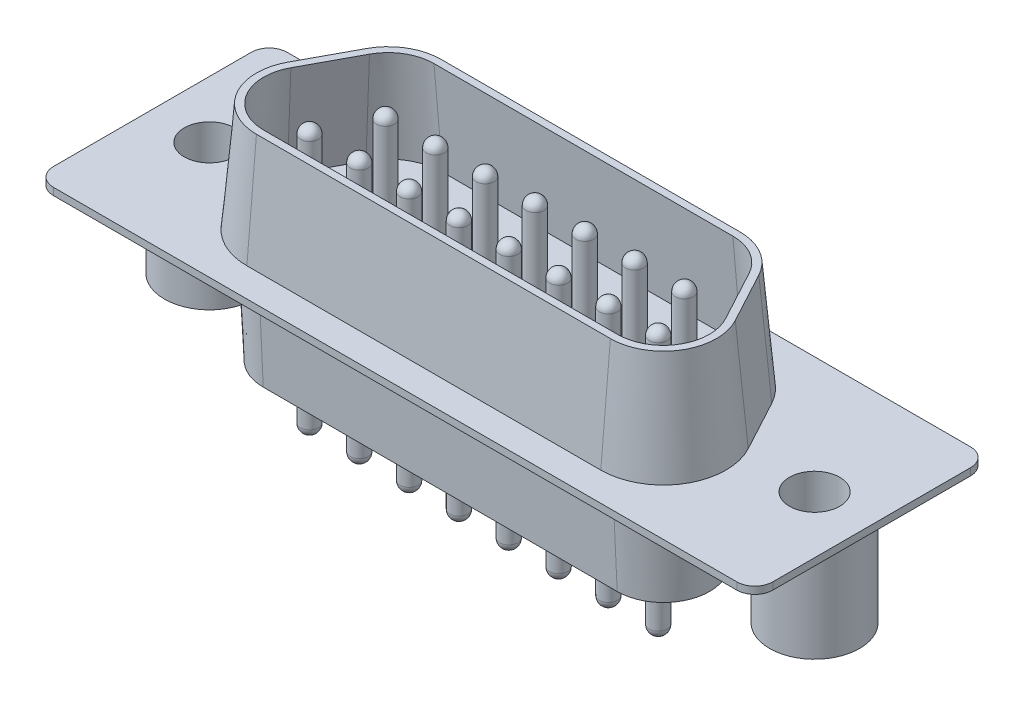
from build123d import *

# Parameters (mm, degrees)
SKETCH1_W                    = 40
SKETCH1_H                    = 0.4
BASE_EXTRUDE_DEPTH           = 5.08
BASE_EXTRUDE_DEPTH_BACK      = 7.92
FILLET1_R                    = 1
SKETCH3_R                    = 2.5
BOSS_EXTRUDE1_DEPTH          = 5.9
SKETCH2_R                    = 1.4
CUT_EXTRUDE1_DEPTH           = 32.509395424
BOSS_EXTRUDE2_DEPTH          = 5.9
BOSS_EXTRUDE2_TAPER          = 2.7
CUT_EXTRUDE2_DEPTH           = 0.01
SKETCH6_R                    = 0.5
BOSS_EXTRUDE3_DEPTH          = 3
DOME1_FACE_RADIUS            = 0.5
DOME1_HEIGHT                 = 0.5
LPATTERN2_COUNT              = 8
LPATTERN2_PITCH              = 2.77
LPATTERN2_COPY_1_FACE_RADIUS = 0.5
LPATTERN2_COPY_1_HEIGHT      = 0.5
LPATTERN2_COPY_2_FACE_RADIUS = 0.5
LPATTERN2_COPY_2_HEIGHT      = 0.5
LPATTERN2_COPY_3_FACE_RADIUS = 0.5
LPATTERN2_COPY_3_HEIGHT      = 0.5
LPATTERN2_COPY_4_FACE_RADIUS = 0.5
LPATTERN2_COPY_4_HEIGHT      = 0.5
LPATTERN2_COPY_5_FACE_RADIUS = 0.5
LPATTERN2_COPY_5_HEIGHT      = 0.5
LPATTERN2_COPY_6_FACE_RADIUS = 0.5
LPATTERN2_COPY_6_HEIGHT      = 0.5
LPATTERN2_COPY_7_FACE_RADIUS = 0.5
LPATTERN2_COPY_7_HEIGHT      = 0.5
SKETCH7_R                    = 0.5
BOSS_EXTRUDE4_DEPTH          = 3
DOME2_FACE_RADIUS            = 0.5
DOME2_HEIGHT                 = 0.5
LPATTERN4_COUNT              = 7
LPATTERN4_PITCH              = 2.77
LPATTERN4_COPY_1_FACE_RADIUS = 0.5
LPATTERN4_COPY_1_HEIGHT      = 0.5
LPATTERN4_COPY_2_FACE_RADIUS = 0.5
LPATTERN4_COPY_2_HEIGHT      = 0.5
LPATTERN4_COPY_3_FACE_RADIUS = 0.5
LPATTERN4_COPY_3_HEIGHT      = 0.5
LPATTERN4_COPY_4_FACE_RADIUS = 0.5
LPATTERN4_COPY_4_HEIGHT      = 0.5
LPATTERN4_COPY_5_FACE_RADIUS = 0.5
LPATTERN4_COPY_5_HEIGHT      = 0.5
LPATTERN4_COPY_6_FACE_RADIUS = 0.5
LPATTERN4_COPY_6_HEIGHT      = 0.5
BOSS_EXTRUDE5_DEPTH          = 6.07
BOSS_EXTRUDE5_TAPER          = 5
CUT_EXTRUDE3_DEPTH           = 5.47
CUT_EXTRUDE3_DRAFT           = 5
SKETCH10_R                   = 0.5
BOSS_EXTRUDE6_DEPTH          = 4
DOME3_FACE_RADIUS            = 0.5
DOME3_HEIGHT                 = 0.5
LPATTERN5_COPY_1_FACE_RADIUS = 0.5
LPATTERN5_COPY_1_HEIGHT      = 0.5
LPATTERN5_COPY_2_FACE_RADIUS = 0.5
LPATTERN5_COPY_2_HEIGHT      = 0.5
LPATTERN5_COPY_3_FACE_RADIUS = 0.5
LPATTERN5_COPY_3_HEIGHT      = 0.5
LPATTERN5_COPY_4_FACE_RADIUS = 0.5
LPATTERN5_COPY_4_HEIGHT      = 0.5
LPATTERN5_COPY_5_FACE_RADIUS = 0.5
LPATTERN5_COPY_5_HEIGHT      = 0.5
LPATTERN5_COPY_6_FACE_RADIUS = 0.5
LPATTERN5_COPY_6_HEIGHT      = 0.5
LPATTERN5_COPY_7_FACE_RADIUS = 0.5
LPATTERN5_COPY_7_HEIGHT      = 0.5
DOME4_FACE_RADIUS            = 0.5
DOME4_HEIGHT                 = 0.5
LPATTERN6_COPY_1_FACE_RADIUS = 0.5
LPATTERN6_COPY_1_HEIGHT      = 0.5
LPATTERN6_COPY_2_FACE_RADIUS = 0.5
LPATTERN6_COPY_2_HEIGHT      = 0.5
LPATTERN6_COPY_3_FACE_RADIUS = 0.5
LPATTERN6_COPY_3_HEIGHT      = 0.5
LPATTERN6_COPY_4_FACE_RADIUS = 0.5
LPATTERN6_COPY_4_HEIGHT      = 0.5
LPATTERN6_COPY_5_FACE_RADIUS = 0.5
LPATTERN6_COPY_5_HEIGHT      = 0.5
LPATTERN6_COPY_6_FACE_RADIUS = 0.5
LPATTERN6_COPY_6_HEIGHT      = 0.5


with BuildPart() as part:
    # Sketch1 → Base-Extrude (new, two sides)
    with BuildSketch(Plane.XY) as base_extrude_sk:
        with Locations((9.84, 6.1)):
            Rectangle(SKETCH1_W, SKETCH1_H)
    extrude(amount=BASE_EXTRUDE_DEPTH)
    extrude(base_extrude_sk.sketch, amount=-BASE_EXTRUDE_DEPTH_BACK)

    # Fillet1
    fillet1_edges = [part.edges().sort_by_distance(p)[0] for p in [
        (29.84, 6.1, 5.08),
        (-10.16, 6.1, -7.92),
        (29.84, 6.1, -7.92),
        (-10.16, 6.1, 5.08),
    ]]
    fillet(fillet1_edges, radius=FILLET1_R)

    # Sketch3 → Boss-Extrude1 (add)
    with BuildSketch(Plane(origin=(0, 5.9, 0), x_dir=(-1, 0, 0), z_dir=(0, 1, 0))):
        with Locations(Location((6.985, -1.42, 0), (0, 0, 90))):
            Circle(SKETCH3_R)
    boss_extrude1 = extrude(amount=-BOSS_EXTRUDE1_DEPTH)

    # Sketch2 → Cut-Extrude1 (cut, through all)
    with BuildSketch(Plane(origin=(0, 6.3, 0), x_dir=(-1, 0, 0), z_dir=(0, 1, 0))):
        with Locations(Location((6.985, -1.42, 0), (0, 0, 90))):
            Circle(SKETCH2_R)
    cut_extrude1 = extrude(amount=-CUT_EXTRUDE1_DEPTH, mode=Mode.SUBTRACT)

    # Mirror1: Boss-Extrude1, Cut-Extrude1 across plane
    add(boss_extrude1.mirror(Plane(origin=(9.84, 0, 0), x_dir=(0, 0, 1), z_dir=(1, 0, 0))))
    add(cut_extrude1.mirror(Plane(origin=(9.84, 0, 0), x_dir=(0, 0, 1), z_dir=(1, 0, 0))), mode=Mode.SUBTRACT)

    # Sketch4 → Boss-Extrude2 (add)
    with BuildSketch(Plane.XZ.offset(-5.9)):
        with BuildLine():
            ThreePointArc((18.15, -5.6892), (19.610774769, -5.286237461), (20.658354599, -4.191331879))
            Line((20.658354599, -4.191331879), (22.188354599, -1.351331879))
            ThreePointArc((22.188354599, -1.351331879), (22.126237461, 1.460774769), (19.68, 2.8492))
            Line((19.68, 2.8492), (0, 2.8492))
            ThreePointArc((0, 2.8492), (-2.446237461, 1.460774769), (-2.508354599, -1.351331879))
            Line((-2.508354599, -1.351331879), (-0.978354599, -4.191331879))
            ThreePointArc((-0.978354599, -4.191331879), (0.069225231, -5.286237461), (1.53, -5.6892))
            Line((1.53, -5.6892), (18.15, -5.6892))
        make_face()
    extrude(amount=BOSS_EXTRUDE2_DEPTH, taper=BOSS_EXTRUDE2_TAPER)

    # Sketch5 → Cut-Extrude2 (cut)
    with BuildSketch(Plane.XZ):
        with BuildLine():
            Line((20.0612541, -3.869654498), (21.5912541, -1.029654498))
            ThreePointArc((21.5912541, -1.029654498), (21.543923617, 1.113045089), (19.68, 2.170963063))
            Line((19.68, 2.170963063), (0, 2.170963063))
            ThreePointArc((0, 2.170963063), (-1.863923617, 1.113045089), (-1.9112541, -1.029654498))
            Line((-1.9112541, -1.029654498), (-0.3812541, -3.869654498))
            ThreePointArc((-0.3812541, -3.869654498), (0.416954911, -4.703923617), (1.53, -5.010963063))
            Line((1.53, -5.010963063), (18.15, -5.010963063))
            ThreePointArc((18.15, -5.010963063), (19.263045089, -4.703923617), (20.0612541, -3.869654498))
        make_face()
    extrude(amount=-CUT_EXTRUDE2_DEPTH, mode=Mode.SUBTRACT)

    # Sketch6 → Boss-Extrude3 (add)
    with BuildSketch(Plane.XZ.offset(-0.01)):
        with Locations(Location((0, 0, 0), (0, 0, 270))):
            Circle(SKETCH6_R)
    boss_extrude3 = extrude(amount=BOSS_EXTRUDE3_DEPTH)

    # Dome1: a dome of height H over a round flat face of radius A is a cap of a sphere of radius (A * A + H * H) / (2 * H)
    dome1_r = (DOME1_FACE_RADIUS * DOME1_FACE_RADIUS + DOME1_HEIGHT * DOME1_HEIGHT) / (2 * DOME1_HEIGHT)
    dome1_base = Plane((0, -2.99, 0), z_dir=(0, -1, 0))
    with Locations(dome1_base.offset(DOME1_HEIGHT - dome1_r)):
        dome1_ball = Sphere(dome1_r, mode=Mode.PRIVATE)
    add(split(dome1_ball, bisect_by=dome1_base, keep=Keep.TOP, mode=Mode.PRIVATE))

    # LPattern2: Boss-Extrude3 ×8
    with Locations(*[(i * LPATTERN2_PITCH, 0, 0) for i in range(1, LPATTERN2_COUNT)]):
        add(boss_extrude3)

    # LPattern2 copy 1: a dome of height H over a round flat face of radius A is a cap of a sphere of radius (A * A + H * H) / (2 * H)
    lpattern2_copy_1_r = (LPATTERN2_COPY_1_FACE_RADIUS * LPATTERN2_COPY_1_FACE_RADIUS + LPATTERN2_COPY_1_HEIGHT * LPATTERN2_COPY_1_HEIGHT) / (2 * LPATTERN2_COPY_1_HEIGHT)
    lpattern2_copy_1_base = Plane((2.77, -2.99, 0), z_dir=(0, -1, 0))
    with Locations(lpattern2_copy_1_base.offset(LPATTERN2_COPY_1_HEIGHT - lpattern2_copy_1_r)):
        lpattern2_copy_1_ball = Sphere(lpattern2_copy_1_r, mode=Mode.PRIVATE)
    add(split(lpattern2_copy_1_ball, bisect_by=lpattern2_copy_1_base, keep=Keep.TOP, mode=Mode.PRIVATE))

    # LPattern2 copy 2: a dome of height H over a round flat face of radius A is a cap of a sphere of radius (A * A + H * H) / (2 * H)
    lpattern2_copy_2_r = (LPATTERN2_COPY_2_FACE_RADIUS * LPATTERN2_COPY_2_FACE_RADIUS + LPATTERN2_COPY_2_HEIGHT * LPATTERN2_COPY_2_HEIGHT) / (2 * LPATTERN2_COPY_2_HEIGHT)
    lpattern2_copy_2_base = Plane((5.54, -2.99, 0), z_dir=(0, -1, 0))
    with Locations(lpattern2_copy_2_base.offset(LPATTERN2_COPY_2_HEIGHT - lpattern2_copy_2_r)):
        lpattern2_copy_2_ball = Sphere(lpattern2_copy_2_r, mode=Mode.PRIVATE)
    add(split(lpattern2_copy_2_ball, bisect_by=lpattern2_copy_2_base, keep=Keep.TOP, mode=Mode.PRIVATE))

    # LPattern2 copy 3: a dome of height H over a round flat face of radius A is a cap of a sphere of radius (A * A + H * H) / (2 * H)
    lpattern2_copy_3_r = (LPATTERN2_COPY_3_FACE_RADIUS * LPATTERN2_COPY_3_FACE_RADIUS + LPATTERN2_COPY_3_HEIGHT * LPATTERN2_COPY_3_HEIGHT) / (2 * LPATTERN2_COPY_3_HEIGHT)
    lpattern2_copy_3_base = Plane((8.31, -2.99, 0), z_dir=(0, -1, 0))
    with Locations(lpattern2_copy_3_base.offset(LPATTERN2_COPY_3_HEIGHT - lpattern2_copy_3_r)):
        lpattern2_copy_3_ball = Sphere(lpattern2_copy_3_r, mode=Mode.PRIVATE)
    add(split(lpattern2_copy_3_ball, bisect_by=lpattern2_copy_3_base, keep=Keep.TOP, mode=Mode.PRIVATE))

    # LPattern2 copy 4: a dome of height H over a round flat face of radius A is a cap of a sphere of radius (A * A + H * H) / (2 * H)
    lpattern2_copy_4_r = (LPATTERN2_COPY_4_FACE_RADIUS * LPATTERN2_COPY_4_FACE_RADIUS + LPATTERN2_COPY_4_HEIGHT * LPATTERN2_COPY_4_HEIGHT) / (2 * LPATTERN2_COPY_4_HEIGHT)
    lpattern2_copy_4_base = Plane((11.08, -2.99, 0), z_dir=(0, -1, 0))
    with Locations(lpattern2_copy_4_base.offset(LPATTERN2_COPY_4_HEIGHT - lpattern2_copy_4_r)):
        lpattern2_copy_4_ball = Sphere(lpattern2_copy_4_r, mode=Mode.PRIVATE)
    add(split(lpattern2_copy_4_ball, bisect_by=lpattern2_copy_4_base, keep=Keep.TOP, mode=Mode.PRIVATE))

    # LPattern2 copy 5: a dome of height H over a round flat face of radius A is a cap of a sphere of radius (A * A + H * H) / (2 * H)
    lpattern2_copy_5_r = (LPATTERN2_COPY_5_FACE_RADIUS * LPATTERN2_COPY_5_FACE_RADIUS + LPATTERN2_COPY_5_HEIGHT * LPATTERN2_COPY_5_HEIGHT) / (2 * LPATTERN2_COPY_5_HEIGHT)
    lpattern2_copy_5_base = Plane((13.85, -2.99, 0), z_dir=(0, -1, 0))
    with Locations(lpattern2_copy_5_base.offset(LPATTERN2_COPY_5_HEIGHT - lpattern2_copy_5_r)):
        lpattern2_copy_5_ball = Sphere(lpattern2_copy_5_r, mode=Mode.PRIVATE)
    add(split(lpattern2_copy_5_ball, bisect_by=lpattern2_copy_5_base, keep=Keep.TOP, mode=Mode.PRIVATE))

    # LPattern2 copy 6: a dome of height H over a round flat face of radius A is a cap of a sphere of radius (A * A + H * H) / (2 * H)
    lpattern2_copy_6_r = (LPATTERN2_COPY_6_FACE_RADIUS * LPATTERN2_COPY_6_FACE_RADIUS + LPATTERN2_COPY_6_HEIGHT * LPATTERN2_COPY_6_HEIGHT) / (2 * LPATTERN2_COPY_6_HEIGHT)
    lpattern2_copy_6_base = Plane((16.62, -2.99, 0), z_dir=(0, -1, 0))
    with Locations(lpattern2_copy_6_base.offset(LPATTERN2_COPY_6_HEIGHT - lpattern2_copy_6_r)):
        lpattern2_copy_6_ball = Sphere(lpattern2_copy_6_r, mode=Mode.PRIVATE)
    add(split(lpattern2_copy_6_ball, bisect_by=lpattern2_copy_6_base, keep=Keep.TOP, mode=Mode.PRIVATE))

    # LPattern2 copy 7: a dome of height H over a round flat face of radius A is a cap of a sphere of radius (A * A + H * H) / (2 * H)
    lpattern2_copy_7_r = (LPATTERN2_COPY_7_FACE_RADIUS * LPATTERN2_COPY_7_FACE_RADIUS + LPATTERN2_COPY_7_HEIGHT * LPATTERN2_COPY_7_HEIGHT) / (2 * LPATTERN2_COPY_7_HEIGHT)
    lpattern2_copy_7_base = Plane((19.39, -2.99, 0), z_dir=(0, -1, 0))
    with Locations(lpattern2_copy_7_base.offset(LPATTERN2_COPY_7_HEIGHT - lpattern2_copy_7_r)):
        lpattern2_copy_7_ball = Sphere(lpattern2_copy_7_r, mode=Mode.PRIVATE)
    add(split(lpattern2_copy_7_ball, bisect_by=lpattern2_copy_7_base, keep=Keep.TOP, mode=Mode.PRIVATE))

    # Sketch7 → Boss-Extrude4 (add)
    with BuildSketch(Plane.XZ.offset(-0.01)):
        with Locations(Location((1.385, -2.84, 0), (0, 0, 270))):
            Circle(SKETCH7_R)
    boss_extrude4 = extrude(amount=BOSS_EXTRUDE4_DEPTH)

    # Dome2: a dome of height H over a round flat face of radius A is a cap of a sphere of radius (A * A + H * H) / (2 * H)
    dome2_r = (DOME2_FACE_RADIUS * DOME2_FACE_RADIUS + DOME2_HEIGHT * DOME2_HEIGHT) / (2 * DOME2_HEIGHT)
    dome2_base = Plane((1.385, -2.99, -2.84), z_dir=(0, -1, 0))
    with Locations(dome2_base.offset(DOME2_HEIGHT - dome2_r)):
        dome2_ball = Sphere(dome2_r, mode=Mode.PRIVATE)
    add(split(dome2_ball, bisect_by=dome2_base, keep=Keep.TOP, mode=Mode.PRIVATE))

    # LPattern4: Boss-Extrude4 ×7
    with Locations(*[(i * LPATTERN4_PITCH, 0, 0) for i in range(1, LPATTERN4_COUNT)]):
        add(boss_extrude4)

    # LPattern4 copy 1: a dome of height H over a round flat face of radius A is a cap of a sphere of radius (A * A + H * H) / (2 * H)
    lpattern4_copy_1_r = (LPATTERN4_COPY_1_FACE_RADIUS * LPATTERN4_COPY_1_FACE_RADIUS + LPATTERN4_COPY_1_HEIGHT * LPATTERN4_COPY_1_HEIGHT) / (2 * LPATTERN4_COPY_1_HEIGHT)
    lpattern4_copy_1_base = Plane((4.155, -2.99, -2.84), z_dir=(0, -1, 0))
    with Locations(lpattern4_copy_1_base.offset(LPATTERN4_COPY_1_HEIGHT - lpattern4_copy_1_r)):
        lpattern4_copy_1_ball = Sphere(lpattern4_copy_1_r, mode=Mode.PRIVATE)
    add(split(lpattern4_copy_1_ball, bisect_by=lpattern4_copy_1_base, keep=Keep.TOP, mode=Mode.PRIVATE))

    # LPattern4 copy 2: a dome of height H over a round flat face of radius A is a cap of a sphere of radius (A * A + H * H) / (2 * H)
    lpattern4_copy_2_r = (LPATTERN4_COPY_2_FACE_RADIUS * LPATTERN4_COPY_2_FACE_RADIUS + LPATTERN4_COPY_2_HEIGHT * LPATTERN4_COPY_2_HEIGHT) / (2 * LPATTERN4_COPY_2_HEIGHT)
    lpattern4_copy_2_base = Plane((6.925, -2.99, -2.84), z_dir=(0, -1, 0))
    with Locations(lpattern4_copy_2_base.offset(LPATTERN4_COPY_2_HEIGHT - lpattern4_copy_2_r)):
        lpattern4_copy_2_ball = Sphere(lpattern4_copy_2_r, mode=Mode.PRIVATE)
    add(split(lpattern4_copy_2_ball, bisect_by=lpattern4_copy_2_base, keep=Keep.TOP, mode=Mode.PRIVATE))

    # LPattern4 copy 3: a dome of height H over a round flat face of radius A is a cap of a sphere of radius (A * A + H * H) / (2 * H)
    lpattern4_copy_3_r = (LPATTERN4_COPY_3_FACE_RADIUS * LPATTERN4_COPY_3_FACE_RADIUS + LPATTERN4_COPY_3_HEIGHT * LPATTERN4_COPY_3_HEIGHT) / (2 * LPATTERN4_COPY_3_HEIGHT)
    lpattern4_copy_3_base = Plane((9.695, -2.99, -2.84), z_dir=(0, -1, 0))
    with Locations(lpattern4_copy_3_base.offset(LPATTERN4_COPY_3_HEIGHT - lpattern4_copy_3_r)):
        lpattern4_copy_3_ball = Sphere(lpattern4_copy_3_r, mode=Mode.PRIVATE)
    add(split(lpattern4_copy_3_ball, bisect_by=lpattern4_copy_3_base, keep=Keep.TOP, mode=Mode.PRIVATE))

    # LPattern4 copy 4: a dome of height H over a round flat face of radius A is a cap of a sphere of radius (A * A + H * H) / (2 * H)
    lpattern4_copy_4_r = (LPATTERN4_COPY_4_FACE_RADIUS * LPATTERN4_COPY_4_FACE_RADIUS + LPATTERN4_COPY_4_HEIGHT * LPATTERN4_COPY_4_HEIGHT) / (2 * LPATTERN4_COPY_4_HEIGHT)
    lpattern4_copy_4_base = Plane((12.465, -2.99, -2.84), z_dir=(0, -1, 0))
    with Locations(lpattern4_copy_4_base.offset(LPATTERN4_COPY_4_HEIGHT - lpattern4_copy_4_r)):
        lpattern4_copy_4_ball = Sphere(lpattern4_copy_4_r, mode=Mode.PRIVATE)
    add(split(lpattern4_copy_4_ball, bisect_by=lpattern4_copy_4_base, keep=Keep.TOP, mode=Mode.PRIVATE))

    # LPattern4 copy 5: a dome of height H over a round flat face of radius A is a cap of a sphere of radius (A * A + H * H) / (2 * H)
    lpattern4_copy_5_r = (LPATTERN4_COPY_5_FACE_RADIUS * LPATTERN4_COPY_5_FACE_RADIUS + LPATTERN4_COPY_5_HEIGHT * LPATTERN4_COPY_5_HEIGHT) / (2 * LPATTERN4_COPY_5_HEIGHT)
    lpattern4_copy_5_base = Plane((15.235, -2.99, -2.84), z_dir=(0, -1, 0))
    with Locations(lpattern4_copy_5_base.offset(LPATTERN4_COPY_5_HEIGHT - lpattern4_copy_5_r)):
        lpattern4_copy_5_ball = Sphere(lpattern4_copy_5_r, mode=Mode.PRIVATE)
    add(split(lpattern4_copy_5_ball, bisect_by=lpattern4_copy_5_base, keep=Keep.TOP, mode=Mode.PRIVATE))

    # LPattern4 copy 6: a dome of height H over a round flat face of radius A is a cap of a sphere of radius (A * A + H * H) / (2 * H)
    lpattern4_copy_6_r = (LPATTERN4_COPY_6_FACE_RADIUS * LPATTERN4_COPY_6_FACE_RADIUS + LPATTERN4_COPY_6_HEIGHT * LPATTERN4_COPY_6_HEIGHT) / (2 * LPATTERN4_COPY_6_HEIGHT)
    lpattern4_copy_6_base = Plane((18.005, -2.99, -2.84), z_dir=(0, -1, 0))
    with Locations(lpattern4_copy_6_base.offset(LPATTERN4_COPY_6_HEIGHT - lpattern4_copy_6_r)):
        lpattern4_copy_6_ball = Sphere(lpattern4_copy_6_r, mode=Mode.PRIVATE)
    add(split(lpattern4_copy_6_ball, bisect_by=lpattern4_copy_6_base, keep=Keep.TOP, mode=Mode.PRIVATE))

    # Sketch8 → Boss-Extrude5 (add)
    with BuildSketch(Plane(origin=(0, 6.3, 0), x_dir=(-1, 0, 0), z_dir=(0, 1, 0))):
        with BuildLine():
            ThreePointArc((-19.68, 3.4811), (-22.668767803, 1.784747665), (-22.744661376, -1.651032361))
            Line((-22.744661376, -1.651032361), (-21.214661376, -4.491032361))
            ThreePointArc((-21.214661376, -4.491032361), (-19.934747665, -5.828767803), (-18.15, -6.3211))
            Line((-18.15, -6.3211), (-1.53, -6.3211))
            ThreePointArc((-1.53, -6.3211), (0.254747665, -5.828767803), (1.534661376, -4.491032361))
            Line((1.534661376, -4.491032361), (3.064661376, -1.651032361))
            ThreePointArc((3.064661376, -1.651032361), (2.988767803, 1.784747665), (0, 3.4811))
            Line((0, 3.4811), (-19.68, 3.4811))
        make_face()
    extrude(amount=BOSS_EXTRUDE5_DEPTH, taper=BOSS_EXTRUDE5_TAPER)


with BuildPart() as cut_extrude3_tool:
    # Sketch9 → Cut-Extrude3 (with draft: the straight prism first)
    with BuildSketch(Plane(origin=(0, 12.37, 0), x_dir=(-1, 0, 0), z_dir=(0, 1, 0))):
        with BuildLine():
            Line((-21.924986004, -1.209446685), (-20.394986004, -4.049446685))
            ThreePointArc((-20.394986004, -4.049446685), (-19.457398449, -5.029390952), (-18.15, -5.390043812))
            Line((-18.15, -5.390043812), (-1.53, -5.390043812))
            ThreePointArc((-1.53, -5.390043812), (-0.222601551, -5.029390952), (0.714986004, -4.049446685))
            Line((0.714986004, -4.049446685), (2.244986004, -1.209446685))
            ThreePointArc((2.244986004, -1.209446685), (2.189390952, 1.307398449), (0, 2.550043812))
            Line((0, 2.550043812), (-19.68, 2.550043812))
            ThreePointArc((-19.68, 2.550043812), (-21.869390952, 1.307398449), (-21.924986004, -1.209446685))
        make_face()
    extrude(amount=-CUT_EXTRUDE3_DEPTH)
    # Cut-Extrude3: the draft: its side faces are tilted about the plane it starts from
    cut_extrude3_sides = [cut_extrude3_tool.faces().sort_by_distance(p)[0] for p in [
        (21.869390952, 9.635, 1.307398449),
        (21.159986004, 9.635, -2.629446685),
        (19.457398449, 9.635, -5.029390952),
        (9.84, 9.635, -5.390043812),
        (0.222601551, 9.635, -5.029390952),
        (-1.479986004, 9.635, -2.629446685),
        (-2.189390952, 9.635, 1.307398449),
        (9.84, 9.635, 2.550043812),
    ]]
    draft(cut_extrude3_sides, Plane(origin=(0, 12.37, 0), x_dir=(-1, 0, 0), z_dir=(0, 1, 0)), CUT_EXTRUDE3_DRAFT)


with BuildPart() as part_1:
    add(part.part)

    # Cut-Extrude3: cut by cut_extrude3_tool
    add(cut_extrude3_tool.part, mode=Mode.SUBTRACT)

    # Sketch10 → Boss-Extrude6 (add)
    with BuildSketch(Plane(origin=(0, 6.9, 0), x_dir=(-1, 0, 0), z_dir=(0, 1, 0))):
        with Locations(Location((-1.385, -2.84, 0), (0, 0, 270))):
            Circle(SKETCH10_R)
        with Locations(Location((-4.155, -2.84, 0), (0, 0, 270))):
            Circle(SKETCH10_R)
        with Locations(Location((-6.925, -2.84, 0), (0, 0, 270))):
            Circle(SKETCH10_R)
        with Locations(Location((-9.695, -2.84, 0), (0, 0, 270))):
            Circle(SKETCH10_R)
        with Locations(Location((-12.465, -2.84, 0), (0, 0, 270))):
            Circle(SKETCH10_R)
        with Locations(Location((-15.235, -2.84, 0), (0, 0, 270))):
            Circle(SKETCH10_R)
        with Locations(Location((-18.005, -2.84, 0), (0, 0, 270))):
            Circle(SKETCH10_R)
        with Locations(Location((-19.39, 0, 0), (0, 0, 270))):
            Circle(SKETCH10_R)
        with Locations(Location((-16.62, 0, 0), (0, 0, 270))):
            Circle(SKETCH10_R)
        with Locations(Location((-13.85, 0, 0), (0, 0, 270))):
            Circle(SKETCH10_R)
        with Locations(Location((-11.08, 0, 0), (0, 0, 270))):
            Circle(SKETCH10_R)
        with Locations(Location((-8.31, 0, 0), (0, 0, 270))):
            Circle(SKETCH10_R)
        with Locations(Location((-5.54, 0, 0), (0, 0, 270))):
            Circle(SKETCH10_R)
        with Locations(Location((-2.77, 0, 0), (0, 0, 270))):
            Circle(SKETCH10_R)
        with Locations(Location((0, 0, 0), (0, 0, 270))):
            Circle(SKETCH10_R)
    extrude(amount=BOSS_EXTRUDE6_DEPTH)

    # Dome3: a dome of height H over a round flat face of radius A is a cap of a sphere of radius (A * A + H * H) / (2 * H)
    dome3_r = (DOME3_FACE_RADIUS * DOME3_FACE_RADIUS + DOME3_HEIGHT * DOME3_HEIGHT) / (2 * DOME3_HEIGHT)
    dome3_base = Plane((0, 10.9, 0), z_dir=(0, 1, 0))
    with Locations(dome3_base.offset(DOME3_HEIGHT - dome3_r)):
        dome3_ball = Sphere(dome3_r, mode=Mode.PRIVATE)
    add(split(dome3_ball, bisect_by=dome3_base, keep=Keep.TOP, mode=Mode.PRIVATE))

    # LPattern5 copy 1: a dome of height H over a round flat face of radius A is a cap of a sphere of radius (A * A + H * H) / (2 * H)
    lpattern5_copy_1_r = (LPATTERN5_COPY_1_FACE_RADIUS * LPATTERN5_COPY_1_FACE_RADIUS + LPATTERN5_COPY_1_HEIGHT * LPATTERN5_COPY_1_HEIGHT) / (2 * LPATTERN5_COPY_1_HEIGHT)
    lpattern5_copy_1_base = Plane((2.77, 10.9, 0), z_dir=(0, 1, 0))
    with Locations(lpattern5_copy_1_base.offset(LPATTERN5_COPY_1_HEIGHT - lpattern5_copy_1_r)):
        lpattern5_copy_1_ball = Sphere(lpattern5_copy_1_r, mode=Mode.PRIVATE)
    add(split(lpattern5_copy_1_ball, bisect_by=lpattern5_copy_1_base, keep=Keep.TOP, mode=Mode.PRIVATE))

    # LPattern5 copy 2: a dome of height H over a round flat face of radius A is a cap of a sphere of radius (A * A + H * H) / (2 * H)
    lpattern5_copy_2_r = (LPATTERN5_COPY_2_FACE_RADIUS * LPATTERN5_COPY_2_FACE_RADIUS + LPATTERN5_COPY_2_HEIGHT * LPATTERN5_COPY_2_HEIGHT) / (2 * LPATTERN5_COPY_2_HEIGHT)
    lpattern5_copy_2_base = Plane((5.54, 10.9, 0), z_dir=(0, 1, 0))
    with Locations(lpattern5_copy_2_base.offset(LPATTERN5_COPY_2_HEIGHT - lpattern5_copy_2_r)):
        lpattern5_copy_2_ball = Sphere(lpattern5_copy_2_r, mode=Mode.PRIVATE)
    add(split(lpattern5_copy_2_ball, bisect_by=lpattern5_copy_2_base, keep=Keep.TOP, mode=Mode.PRIVATE))

    # LPattern5 copy 3: a dome of height H over a round flat face of radius A is a cap of a sphere of radius (A * A + H * H) / (2 * H)
    lpattern5_copy_3_r = (LPATTERN5_COPY_3_FACE_RADIUS * LPATTERN5_COPY_3_FACE_RADIUS + LPATTERN5_COPY_3_HEIGHT * LPATTERN5_COPY_3_HEIGHT) / (2 * LPATTERN5_COPY_3_HEIGHT)
    lpattern5_copy_3_base = Plane((8.31, 10.9, 0), z_dir=(0, 1, 0))
    with Locations(lpattern5_copy_3_base.offset(LPATTERN5_COPY_3_HEIGHT - lpattern5_copy_3_r)):
        lpattern5_copy_3_ball = Sphere(lpattern5_copy_3_r, mode=Mode.PRIVATE)
    add(split(lpattern5_copy_3_ball, bisect_by=lpattern5_copy_3_base, keep=Keep.TOP, mode=Mode.PRIVATE))

    # LPattern5 copy 4: a dome of height H over a round flat face of radius A is a cap of a sphere of radius (A * A + H * H) / (2 * H)
    lpattern5_copy_4_r = (LPATTERN5_COPY_4_FACE_RADIUS * LPATTERN5_COPY_4_FACE_RADIUS + LPATTERN5_COPY_4_HEIGHT * LPATTERN5_COPY_4_HEIGHT) / (2 * LPATTERN5_COPY_4_HEIGHT)
    lpattern5_copy_4_base = Plane((11.08, 10.9, 0), z_dir=(0, 1, 0))
    with Locations(lpattern5_copy_4_base.offset(LPATTERN5_COPY_4_HEIGHT - lpattern5_copy_4_r)):
        lpattern5_copy_4_ball = Sphere(lpattern5_copy_4_r, mode=Mode.PRIVATE)
    add(split(lpattern5_copy_4_ball, bisect_by=lpattern5_copy_4_base, keep=Keep.TOP, mode=Mode.PRIVATE))

    # LPattern5 copy 5: a dome of height H over a round flat face of radius A is a cap of a sphere of radius (A * A + H * H) / (2 * H)
    lpattern5_copy_5_r = (LPATTERN5_COPY_5_FACE_RADIUS * LPATTERN5_COPY_5_FACE_RADIUS + LPATTERN5_COPY_5_HEIGHT * LPATTERN5_COPY_5_HEIGHT) / (2 * LPATTERN5_COPY_5_HEIGHT)
    lpattern5_copy_5_base = Plane((13.85, 10.9, 0), z_dir=(0, 1, 0))
    with Locations(lpattern5_copy_5_base.offset(LPATTERN5_COPY_5_HEIGHT - lpattern5_copy_5_r)):
        lpattern5_copy_5_ball = Sphere(lpattern5_copy_5_r, mode=Mode.PRIVATE)
    add(split(lpattern5_copy_5_ball, bisect_by=lpattern5_copy_5_base, keep=Keep.TOP, mode=Mode.PRIVATE))

    # LPattern5 copy 6: a dome of height H over a round flat face of radius A is a cap of a sphere of radius (A * A + H * H) / (2 * H)
    lpattern5_copy_6_r = (LPATTERN5_COPY_6_FACE_RADIUS * LPATTERN5_COPY_6_FACE_RADIUS + LPATTERN5_COPY_6_HEIGHT * LPATTERN5_COPY_6_HEIGHT) / (2 * LPATTERN5_COPY_6_HEIGHT)
    lpattern5_copy_6_base = Plane((16.62, 10.9, 0), z_dir=(0, 1, 0))
    with Locations(lpattern5_copy_6_base.offset(LPATTERN5_COPY_6_HEIGHT - lpattern5_copy_6_r)):
        lpattern5_copy_6_ball = Sphere(lpattern5_copy_6_r, mode=Mode.PRIVATE)
    add(split(lpattern5_copy_6_ball, bisect_by=lpattern5_copy_6_base, keep=Keep.TOP, mode=Mode.PRIVATE))

    # LPattern5 copy 7: a dome of height H over a round flat face of radius A is a cap of a sphere of radius (A * A + H * H) / (2 * H)
    lpattern5_copy_7_r = (LPATTERN5_COPY_7_FACE_RADIUS * LPATTERN5_COPY_7_FACE_RADIUS + LPATTERN5_COPY_7_HEIGHT * LPATTERN5_COPY_7_HEIGHT) / (2 * LPATTERN5_COPY_7_HEIGHT)
    lpattern5_copy_7_base = Plane((19.39, 10.9, 0), z_dir=(0, 1, 0))
    with Locations(lpattern5_copy_7_base.offset(LPATTERN5_COPY_7_HEIGHT - lpattern5_copy_7_r)):
        lpattern5_copy_7_ball = Sphere(lpattern5_copy_7_r, mode=Mode.PRIVATE)
    add(split(lpattern5_copy_7_ball, bisect_by=lpattern5_copy_7_base, keep=Keep.TOP, mode=Mode.PRIVATE))

    # Dome4: a dome of height H over a round flat face of radius A is a cap of a sphere of radius (A * A + H * H) / (2 * H)
    dome4_r = (DOME4_FACE_RADIUS * DOME4_FACE_RADIUS + DOME4_HEIGHT * DOME4_HEIGHT) / (2 * DOME4_HEIGHT)
    dome4_base = Plane((1.385, 10.9, -2.84), z_dir=(0, 1, 0))
    with Locations(dome4_base.offset(DOME4_HEIGHT - dome4_r)):
        dome4_ball = Sphere(dome4_r, mode=Mode.PRIVATE)
    add(split(dome4_ball, bisect_by=dome4_base, keep=Keep.TOP, mode=Mode.PRIVATE))

    # LPattern6 copy 1: a dome of height H over a round flat face of radius A is a cap of a sphere of radius (A * A + H * H) / (2 * H)
    lpattern6_copy_1_r = (LPATTERN6_COPY_1_FACE_RADIUS * LPATTERN6_COPY_1_FACE_RADIUS + LPATTERN6_COPY_1_HEIGHT * LPATTERN6_COPY_1_HEIGHT) / (2 * LPATTERN6_COPY_1_HEIGHT)
    lpattern6_copy_1_base = Plane((4.155, 10.9, -2.84), z_dir=(0, 1, 0))
    with Locations(lpattern6_copy_1_base.offset(LPATTERN6_COPY_1_HEIGHT - lpattern6_copy_1_r)):
        lpattern6_copy_1_ball = Sphere(lpattern6_copy_1_r, mode=Mode.PRIVATE)
    add(split(lpattern6_copy_1_ball, bisect_by=lpattern6_copy_1_base, keep=Keep.TOP, mode=Mode.PRIVATE))

    # LPattern6 copy 2: a dome of height H over a round flat face of radius A is a cap of a sphere of radius (A * A + H * H) / (2 * H)
    lpattern6_copy_2_r = (LPATTERN6_COPY_2_FACE_RADIUS * LPATTERN6_COPY_2_FACE_RADIUS + LPATTERN6_COPY_2_HEIGHT * LPATTERN6_COPY_2_HEIGHT) / (2 * LPATTERN6_COPY_2_HEIGHT)
    lpattern6_copy_2_base = Plane((6.925, 10.9, -2.84), z_dir=(0, 1, 0))
    with Locations(lpattern6_copy_2_base.offset(LPATTERN6_COPY_2_HEIGHT - lpattern6_copy_2_r)):
        lpattern6_copy_2_ball = Sphere(lpattern6_copy_2_r, mode=Mode.PRIVATE)
    add(split(lpattern6_copy_2_ball, bisect_by=lpattern6_copy_2_base, keep=Keep.TOP, mode=Mode.PRIVATE))

    # LPattern6 copy 3: a dome of height H over a round flat face of radius A is a cap of a sphere of radius (A * A + H * H) / (2 * H)
    lpattern6_copy_3_r = (LPATTERN6_COPY_3_FACE_RADIUS * LPATTERN6_COPY_3_FACE_RADIUS + LPATTERN6_COPY_3_HEIGHT * LPATTERN6_COPY_3_HEIGHT) / (2 * LPATTERN6_COPY_3_HEIGHT)
    lpattern6_copy_3_base = Plane((9.695, 10.9, -2.84), z_dir=(0, 1, 0))
    with Locations(lpattern6_copy_3_base.offset(LPATTERN6_COPY_3_HEIGHT - lpattern6_copy_3_r)):
        lpattern6_copy_3_ball = Sphere(lpattern6_copy_3_r, mode=Mode.PRIVATE)
    add(split(lpattern6_copy_3_ball, bisect_by=lpattern6_copy_3_base, keep=Keep.TOP, mode=Mode.PRIVATE))

    # LPattern6 copy 4: a dome of height H over a round flat face of radius A is a cap of a sphere of radius (A * A + H * H) / (2 * H)
    lpattern6_copy_4_r = (LPATTERN6_COPY_4_FACE_RADIUS * LPATTERN6_COPY_4_FACE_RADIUS + LPATTERN6_COPY_4_HEIGHT * LPATTERN6_COPY_4_HEIGHT) / (2 * LPATTERN6_COPY_4_HEIGHT)
    lpattern6_copy_4_base = Plane((12.465, 10.9, -2.84), z_dir=(0, 1, 0))
    with Locations(lpattern6_copy_4_base.offset(LPATTERN6_COPY_4_HEIGHT - lpattern6_copy_4_r)):
        lpattern6_copy_4_ball = Sphere(lpattern6_copy_4_r, mode=Mode.PRIVATE)
    add(split(lpattern6_copy_4_ball, bisect_by=lpattern6_copy_4_base, keep=Keep.TOP, mode=Mode.PRIVATE))

    # LPattern6 copy 5: a dome of height H over a round flat face of radius A is a cap of a sphere of radius (A * A + H * H) / (2 * H)
    lpattern6_copy_5_r = (LPATTERN6_COPY_5_FACE_RADIUS * LPATTERN6_COPY_5_FACE_RADIUS + LPATTERN6_COPY_5_HEIGHT * LPATTERN6_COPY_5_HEIGHT) / (2 * LPATTERN6_COPY_5_HEIGHT)
    lpattern6_copy_5_base = Plane((15.235, 10.9, -2.84), z_dir=(0, 1, 0))
    with Locations(lpattern6_copy_5_base.offset(LPATTERN6_COPY_5_HEIGHT - lpattern6_copy_5_r)):
        lpattern6_copy_5_ball = Sphere(lpattern6_copy_5_r, mode=Mode.PRIVATE)
    add(split(lpattern6_copy_5_ball, bisect_by=lpattern6_copy_5_base, keep=Keep.TOP, mode=Mode.PRIVATE))

    # LPattern6 copy 6: a dome of height H over a round flat face of radius A is a cap of a sphere of radius (A * A + H * H) / (2 * H)
    lpattern6_copy_6_r = (LPATTERN6_COPY_6_FACE_RADIUS * LPATTERN6_COPY_6_FACE_RADIUS + LPATTERN6_COPY_6_HEIGHT * LPATTERN6_COPY_6_HEIGHT) / (2 * LPATTERN6_COPY_6_HEIGHT)
    lpattern6_copy_6_base = Plane((18.005, 10.9, -2.84), z_dir=(0, 1, 0))
    with Locations(lpattern6_copy_6_base.offset(LPATTERN6_COPY_6_HEIGHT - lpattern6_copy_6_r)):
        lpattern6_copy_6_ball = Sphere(lpattern6_copy_6_r, mode=Mode.PRIVATE)
    add(split(lpattern6_copy_6_ball, bisect_by=lpattern6_copy_6_base, keep=Keep.TOP, mode=Mode.PRIVATE))


solid = part_1.part
